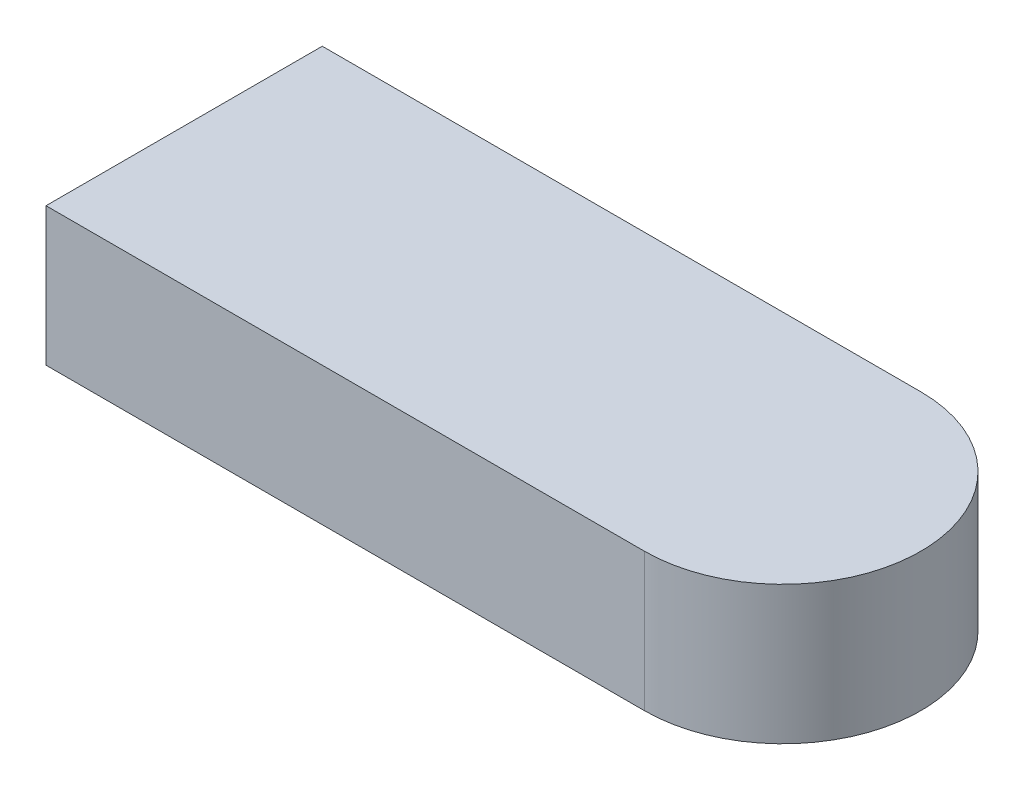
from build123d import *

# Parameters (mm, degrees)
SKETCH2_W           = 80
SKETCH2_H           = 30
BOSS_EXTRUDE1_DEPTH = 15
CUT_EXTRUDE4_DEPTH  = 16
CUT_EXTRUDE5_DEPTH  = 16


with BuildPart() as part:
    # Sketch2 → Boss-Extrude1 (new body)
    with BuildSketch(Plane(origin=(0, 0, 0), x_dir=(1, 0, 0), z_dir=(0, 1, 0))):
        Rectangle(SKETCH2_W, SKETCH2_H)
    extrude(amount=BOSS_EXTRUDE1_DEPTH)

    # Sketch4 → Cut-Extrude4 (cut, through all)
    with BuildSketch(Plane(origin=(0, 15, 0), x_dir=(1, 0, 0), z_dir=(0, 1, 0))):
        with BuildLine():
            Line((25, 15), (40, 15))
            Line((40, 15), (40, 0))
            ThreePointArc((40, 0), (35.606601718, 10.606601718), (25, 15))
        make_face()
    extrude(amount=-CUT_EXTRUDE4_DEPTH, mode=Mode.SUBTRACT)

    # Sketch5 → Cut-Extrude5 (cut, through all)
    with BuildSketch(Plane(origin=(0, 15, 0), x_dir=(1, 0, 0), z_dir=(0, 1, 0))):
        with BuildLine():
            Line((40, 0), (40, -15))
            Line((40, -15), (25, -15))
            ThreePointArc((25, -15), (35.606601718, -10.606601718), (40, 0))
        make_face()
    extrude(amount=-CUT_EXTRUDE5_DEPTH, mode=Mode.SUBTRACT)


solid = part.part
